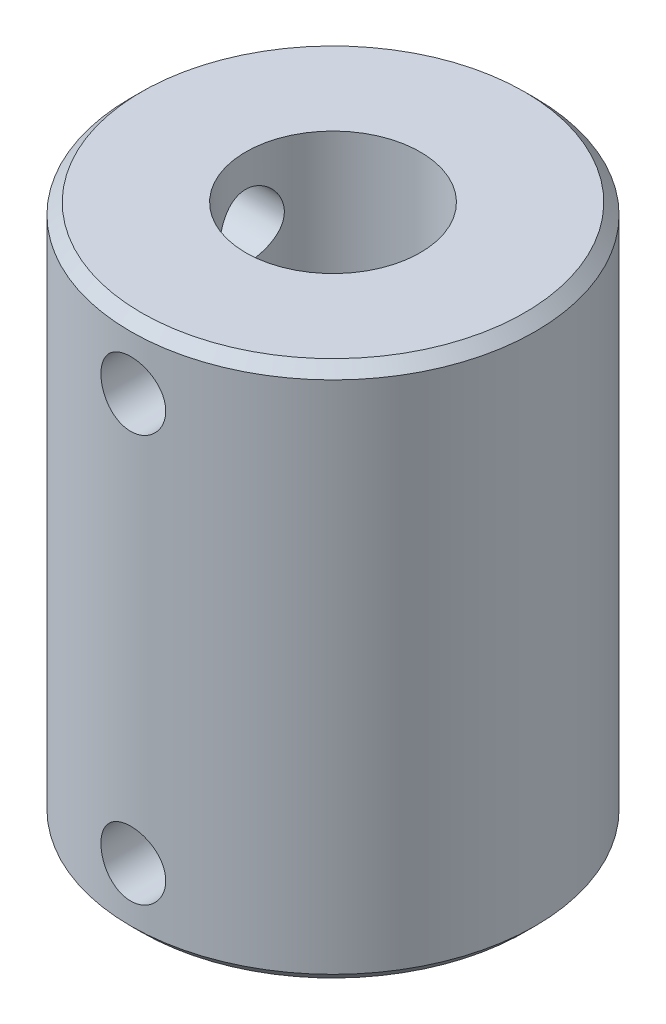
from build123d import *

# Parameters (mm, degrees)
SKETCH1_R           = 9.36
BOSS_EXTRUDE1_DEPTH = 24.82
SKETCH2_R           = 2.545
CUT_EXTRUDE1_DEPTH  = 25.82
CUT_EXTRUDE2_START  = 24.82
SKETCH2_3_R         = 4.04
SKETCH2_3_R_2       = 2.545
CUT_EXTRUDE2_DEPTH  = 18.28
CHAMFER1_SIZE       = 0.5
SKETCH3_R           = 1.5
CUT_EXTRUDE3_DEPTH  = 18.28
CIRPATTERN1_COUNT   = 2
CIRPATTERN1_ANGLE   = 90


with BuildPart() as part:
    # Sketch1 → Boss-Extrude1 (new body)
    with BuildSketch(Plane(origin=(0, 0, 0), x_dir=(1, 0, 0), z_dir=(0, 1, 0))):
        Circle(SKETCH1_R)
    extrude(amount=BOSS_EXTRUDE1_DEPTH)

    # Sketch2 → Cut-Extrude1 (cut, through all)
    with BuildSketch(Plane(origin=(0, 0, 0), x_dir=(1, 0, 0), z_dir=(0, 1, 0))):
        Circle(SKETCH2_R)
    extrude(amount=CUT_EXTRUDE1_DEPTH, mode=Mode.SUBTRACT)

    # Sketch2_3 → Cut-Extrude2 (cut)
    with BuildSketch(Plane(origin=(0, 0, 0), x_dir=(1, 0, 0), z_dir=(0, 1, 0)).offset(CUT_EXTRUDE2_START)):
        Circle(SKETCH2_3_R)
        Circle(SKETCH2_3_R_2, mode=Mode.SUBTRACT)
    extrude(amount=-CUT_EXTRUDE2_DEPTH, mode=Mode.SUBTRACT)

    # Chamfer1
    chamfer1_edges = [part.edges().sort_by_distance(p)[0] for p in [
        (-9.36, 0, 0),
        (-9.36, 24.82, 0),
    ]]
    chamfer(chamfer1_edges, length=CHAMFER1_SIZE)

    # Sketch3 → Cut-Extrude3 (cut)
    with BuildSketch(Plane(origin=(0, 0, 0), x_dir=(0, 0, -1), z_dir=(1, 0, 0))):
        with Locations((0, 21.82)):
            Circle(SKETCH3_R)
        with Locations((0, 3)):
            Circle(SKETCH3_R)
    cut_extrude3 = extrude(amount=-CUT_EXTRUDE3_DEPTH, mode=Mode.SUBTRACT)

    # CirPattern1: Cut-Extrude3 ×2 about axis
    cirpattern1_axis = Axis((0, 24.82, 0), (0, 1, 0))
    for i in range(1, CIRPATTERN1_COUNT):
        add(cut_extrude3.rotate(cirpattern1_axis, i * CIRPATTERN1_ANGLE / (CIRPATTERN1_COUNT - 1)), mode=Mode.SUBTRACT)


solid = part.part
